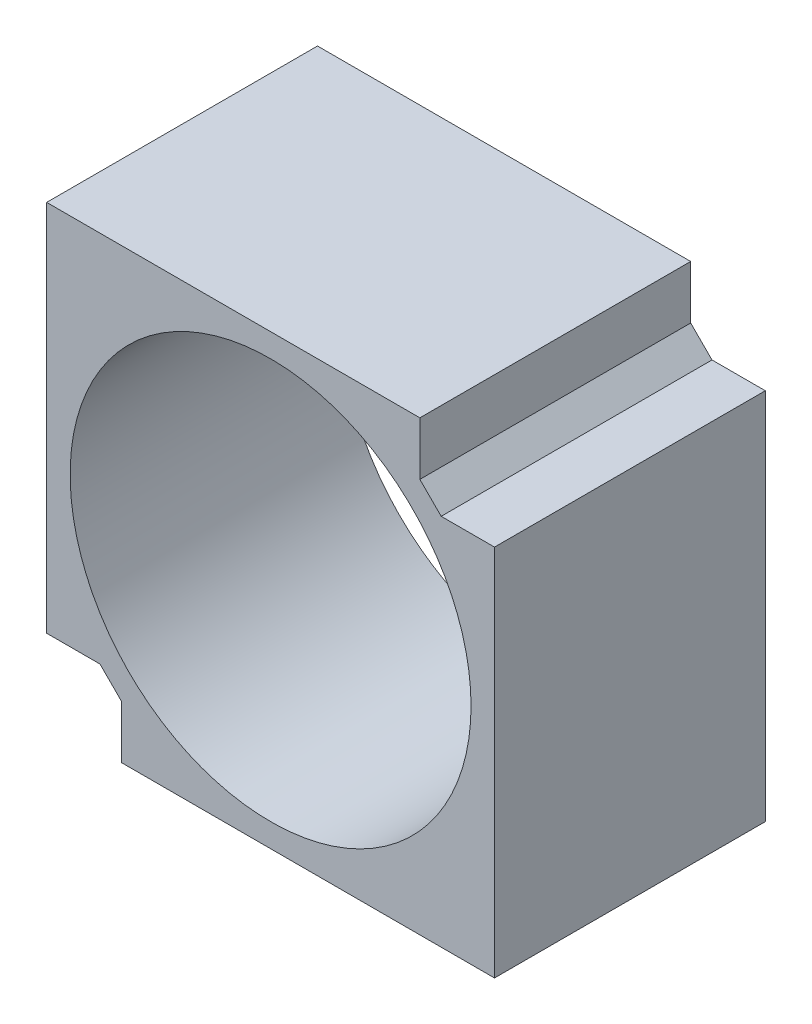
from build123d import *

# Parameters (mm, degrees)
BOSS_EXTRUDE1_DEPTH = 25.4
CUT_EXTRUDE1_DEPTH  = 25.4
CUT_EXTRUDE2_DEPTH  = 25.4
SKETCH4_R           = 18.8
CUT_EXTRUDE3_DEPTH  = 25.4


with BuildPart() as part:
    # Sketch1 → Boss-Extrude1 (new body)
    with BuildSketch(Plane.XY):
        Polygon((0, 21), (21, 21), (21, -21), (-21, -21), (-21, 21), align=None)
    extrude(amount=BOSS_EXTRUDE1_DEPTH)

    # Sketch2 → Cut-Extrude1 (cut)
    with BuildSketch(Plane.XY.offset(25.4)):
        Polygon((21, 21), (21, 14), (16, 14), (14, 16), (14, 21), align=None)
    extrude(amount=-CUT_EXTRUDE1_DEPTH, mode=Mode.SUBTRACT)

    # Sketch3 → Cut-Extrude2 (cut)
    with BuildSketch(Plane.XY.offset(25.4)):
        Polygon((-14, -16), (-16, -14), (-21, -14), (-21, -21), (-14, -21), align=None)
    extrude(amount=-CUT_EXTRUDE2_DEPTH, mode=Mode.SUBTRACT)

    # Sketch4 → Cut-Extrude3 (cut)
    with BuildSketch(Plane.XY.offset(25.4)):
        Circle(SKETCH4_R)
    extrude(amount=-CUT_EXTRUDE3_DEPTH, mode=Mode.SUBTRACT)


solid = part.part
